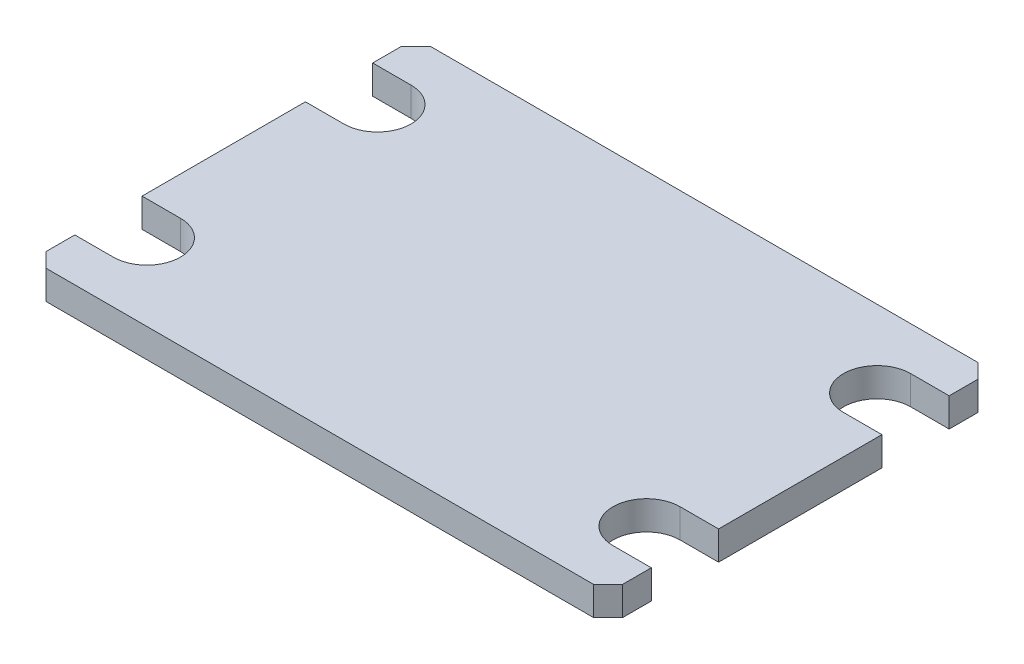
from build123d import *

# Parameters (mm, degrees)
SKETCH1_W               = 381
SKETCH1_H               = 254
BASE_EXTRUDE_DEPTH      = 19.05
CUT_EXTRUDE1_DEPTH      = 20.05
CUT_EXTRUDE2_DEPTH      = 128
CUT_EXTRUDE2_DEPTH_BACK = 128
CHAMFER1_SIZE           = 9.525


with BuildPart() as part:
    # Sketch1 → Base-Extrude (new body)
    with BuildSketch(Plane(origin=(0, 0, 0), x_dir=(1, 0, 0), z_dir=(0, 1, 0))):
        Rectangle(SKETCH1_W, SKETCH1_H)
    extrude(amount=BASE_EXTRUDE_DEPTH)

    # Sketch2 → Boss-Revolve1 (revolve)
    with BuildSketch(Plane(origin=(0, 0, 0), x_dir=(0, 0, -1), z_dir=(1, 0, 0)), mode=Mode.PRIVATE) as boss_revolve1_sk:
        with BuildLine():
            Line((0, -31.75), (0, 0))
            Line((0, 0), (122.967221242, 0))
            ThreePointArc((122.967221242, 0), (63.5, -23.684442484), (0, -31.75))
        make_face()
    revolve(boss_revolve1_sk.sketch.rotate(Axis((0, -41.201658399, 0), (0, 1, 0)), 180), axis=Axis((0, -41.201658399, 0), (0, 1, 0)))  # turned: the seam where the file's is

    # Sketch4 → Cut-Extrude1 (cut, through all)
    with BuildSketch(Plane.XZ):
        with BuildLine():
            Line((-190.5, 53.975), (-165.1, 53.975))
            ThreePointArc((-165.1, 53.975), (-142.875, 76.2), (-165.1, 98.425))
            Line((-165.1, 98.425), (-190.5, 98.425))
            Line((-190.5, 98.425), (-190.5, 53.975))
        make_face()
        with BuildLine():
            Line((-190.5, -98.425), (-165.1, -98.425))
            ThreePointArc((-165.1, -98.425), (-142.875, -76.2), (-165.1, -53.975))
            Line((-165.1, -53.975), (-190.5, -53.975))
            Line((-190.5, -53.975), (-190.5, -98.425))
        make_face()
        with BuildLine():
            Line((190.5, -98.425), (165.1, -98.425))
            ThreePointArc((165.1, -98.425), (142.875, -76.2), (165.1, -53.975))
            Line((165.1, -53.975), (190.5, -53.975))
            Line((190.5, -53.975), (190.5, -98.425))
        make_face()
        with BuildLine():
            Line((165.1, 53.975), (190.5, 53.975))
            Line((190.5, 53.975), (190.5, 98.425))
            Line((190.5, 98.425), (165.1, 98.425))
            ThreePointArc((165.1, 98.425), (142.875, 76.2), (165.1, 53.975))
        make_face()
    extrude(amount=-CUT_EXTRUDE1_DEPTH, mode=Mode.SUBTRACT)

    # Sketch5 → Cut-Extrude2 (cut, two sides)
    with BuildSketch(Plane.XY) as cut_extrude2_sk:
        with BuildLine():
            Line((56.44003455, -25.4), (-56.44003455, -25.4))
            ThreePointArc((-56.44003455, -25.4), (0, -31.75), (56.44003455, -25.4))
        make_face()
    extrude(amount=CUT_EXTRUDE2_DEPTH, mode=Mode.SUBTRACT)
    extrude(cut_extrude2_sk.sketch, amount=-CUT_EXTRUDE2_DEPTH_BACK, mode=Mode.SUBTRACT)

    # Chamfer1
    chamfer1_edges = [part.edges().sort_by_distance(p)[0] for p in [
        (-190.5, 9.525, 127),
        (190.5, 9.525, 127),
        (190.5, 9.525, -127),
        (-190.5, 9.525, -127),
    ]]
    chamfer(chamfer1_edges, length=CHAMFER1_SIZE)


solid = part.part
